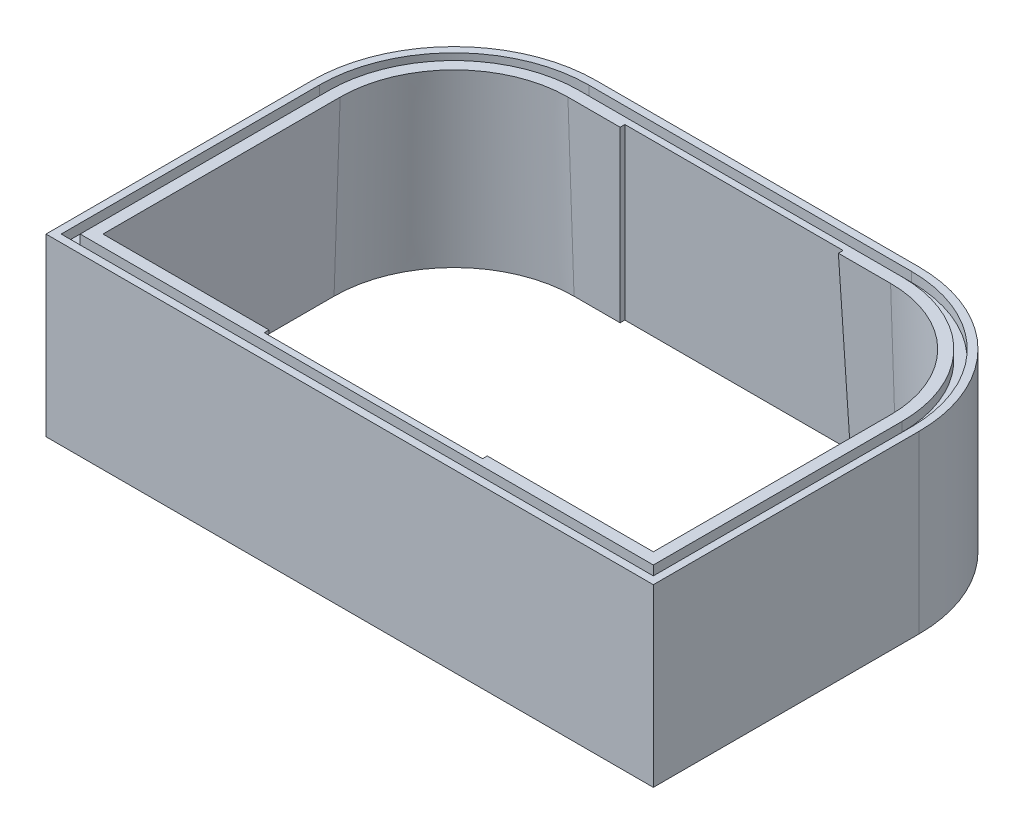
from build123d import *

# Parameters (mm, degrees)
SKIZZE1_W                            = 640
SKIZZE1_H                            = 430
AUFSATZ_LINEAR_AUSTRAGEN1_DEPTH      = 185
VERRUNDUNG1_R                        = 150
SCHNITT_LINEAR_AUSTRAGEN1_DEPTH      = 186
SCHNITT_LINEAR_AUSTRAGEN1_DRAFT      = 2
SCHNITT_LINEAR_AUSTRAGEN_D_NN1_DEPTH = 10


with BuildPart() as part:
    # Skizze1 → Aufsatz-Linear austragen1 (new body)
    with BuildSketch(Plane(origin=(0, 0, 0), x_dir=(1, 0, 0), z_dir=(0, 1, 0))):
        with Locations((320, 215)):
            Rectangle(SKIZZE1_W, SKIZZE1_H)
    extrude(amount=AUFSATZ_LINEAR_AUSTRAGEN1_DEPTH)

    # Verrundung1
    verrundung1_edges = [part.edges().sort_by_distance(p)[0] for p in [
        (0, 92.5, -430),
        (640, 92.5, -430),
    ]]
    fillet(verrundung1_edges, radius=VERRUNDUNG1_R)


with BuildPart() as schnitt_linear_austragen1_tool:
    # Skizze2 → Schnitt-Linear austragen1 (with draft: the straight prism first)
    with BuildSketch(Plane(origin=(0, 185, 0), x_dir=(1, 0, 0), z_dir=(0, 1, 0))):
        with BuildLine():
            Line((490, 400), (435, 400))
            Line((435, 400), (435, 405))
            Line((435, 405), (205, 405))
            Line((205, 405), (205, 400))
            Line((205, 400), (150, 400))
            ThreePointArc((150, 400), (65.147186258, 364.852813742), (30, 280))
            Line((30, 280), (30, 30))
            Line((30, 30), (205, 30))
            Line((205, 30), (205, 25))
            Line((205, 25), (435, 25))
            Line((435, 25), (435, 30))
            Line((435, 30), (610, 30))
            Line((610, 30), (610, 280))
            ThreePointArc((610, 280), (574.852813742, 364.852813742), (490, 400))
        make_face()
    extrude(amount=-SCHNITT_LINEAR_AUSTRAGEN1_DEPTH)
    # Schnitt-Linear austragen1: the draft: its side faces are tilted about the plane it starts from
    schnitt_linear_austragen1_sides = [schnitt_linear_austragen1_tool.faces().sort_by_distance(p)[0] for p in [
        (462.5, 92, -400),
        (435, 92, -402.5),
        (320, 92, -405),
        (205, 92, -402.5),
        (177.5, 92, -400),
        (65.147186258, 92, -364.852813742),
        (30, 92, -155),
        (117.5, 92, -30),
        (205, 92, -27.5),
        (320, 92, -25),
        (435, 92, -27.5),
        (522.5, 92, -30),
        (610, 92, -155),
        (574.852813742, 92, -364.852813742),
    ]]
    draft(schnitt_linear_austragen1_sides, Plane(origin=(0, 185, 0), x_dir=(1, 0, 0), z_dir=(0, 1, 0)), SCHNITT_LINEAR_AUSTRAGEN1_DRAFT)


with BuildPart() as part_1:
    add(part.part)

    # Schnitt-Linear austragen1: cut by schnitt_linear_austragen1_tool
    add(schnitt_linear_austragen1_tool.part, mode=Mode.SUBTRACT)

    # Skizze3 → Schnitt-Linear-Austragen-Dünn1 (cut)
    with BuildSketch(Plane(origin=(0, 185, 0), x_dir=(1, 0, 0), z_dir=(0, 1, 0))):
        with BuildLine():
            Line((490, 422), (150, 422))
            ThreePointArc((150, 422), (49.590837072, 380.409162928), (8, 280))
            Line((8, 280), (8, 8))
            Line((8, 8), (632, 8))
            Line((632, 8), (632, 280))
            ThreePointArc((632, 280), (590.409162928, 380.409162928), (490, 422))
        make_face()
        with BuildLine():
            Line((490, 412), (150, 412))
            ThreePointArc((150, 412), (56.661904883, 373.338095117), (18, 280))
            Line((18, 280), (18, 18))
            Line((18, 18), (622, 18))
            Line((622, 18), (622, 280))
            ThreePointArc((622, 280), (583.338095117, 373.338095117), (490, 412))
        make_face(mode=Mode.SUBTRACT)
    extrude(amount=-SCHNITT_LINEAR_AUSTRAGEN_D_NN1_DEPTH, mode=Mode.SUBTRACT)


solid = part_1.part
